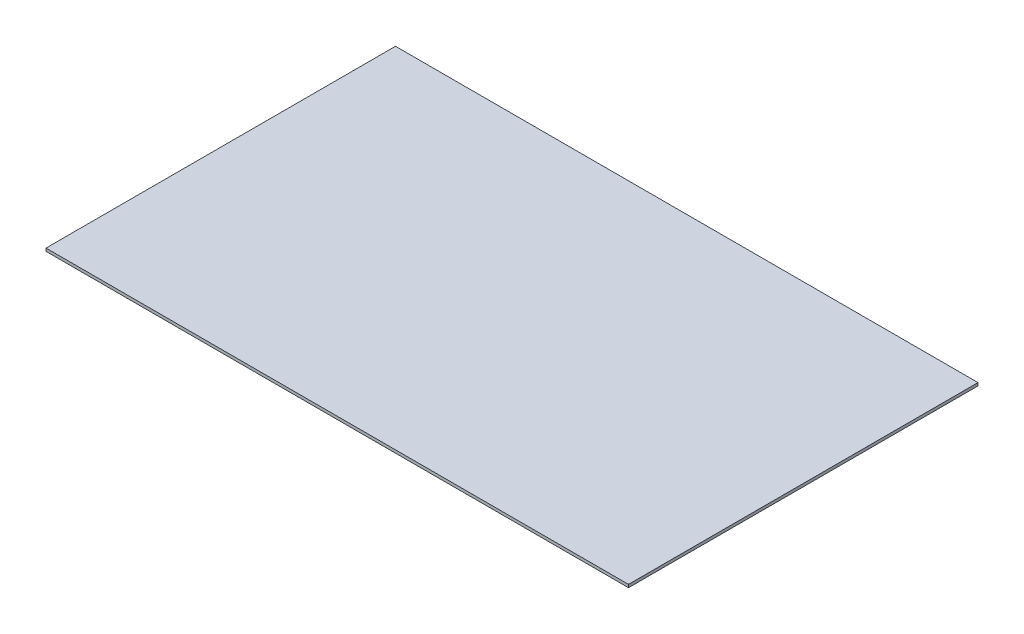
from build123d import *

# Parameters (mm, degrees)
SKETCH1_W               = 508
SKETCH1_H               = 304.8
NEW_BOARD_12X22IN_DEPTH = 2.54


with BuildPart() as part:
    # Sketch1 → New Board 12x22in (new body)
    with BuildSketch(Plane(origin=(0, 0, 0), x_dir=(1, 0, 0), z_dir=(0, 1, 0))):
        Rectangle(SKETCH1_W, SKETCH1_H)
    extrude(amount=NEW_BOARD_12X22IN_DEPTH)


solid = part.part
